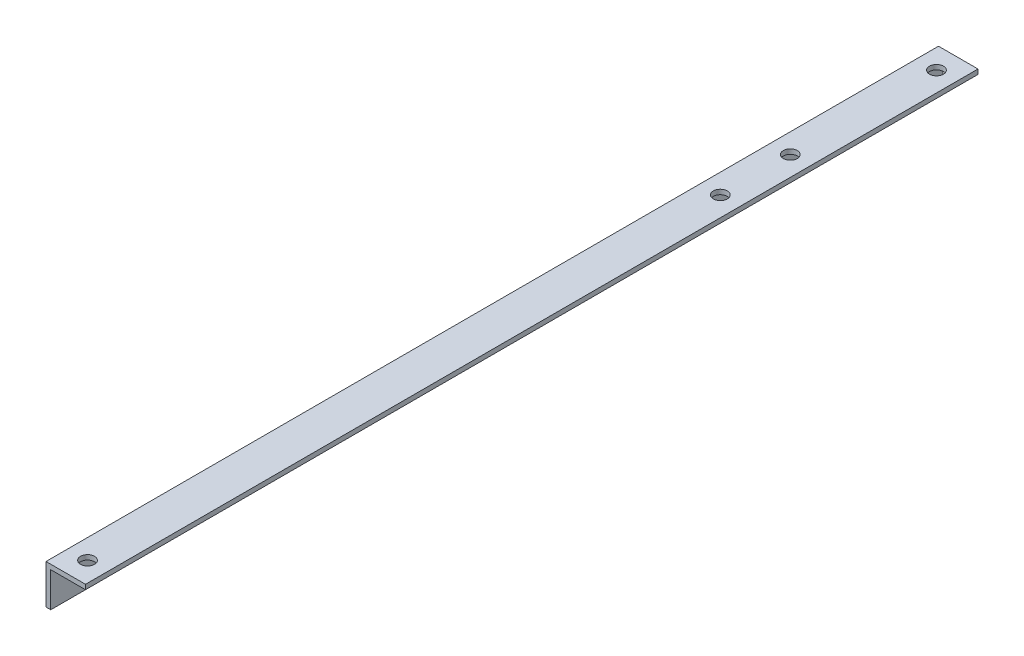
from build123d import *

# Parameters (mm, degrees)
BOSS_EXTRUDE1_DEPTH  = 287
M4_CLEARANCE_HOLE1_D = 4.5
M4_CLEARANCE_HOLE2_D = 4.5


with BuildPart() as part:
    # Sketch1 → Boss-Extrude1 (new body)
    with BuildSketch(Plane.XY):
        Polygon((0, 0), (12.7, 0), (12.7, -1.524), (1.524, -1.524), (1.524, -12.7), (0, -12.7), align=None)
    extrude(amount=BOSS_EXTRUDE1_DEPTH)

    # M4 Clearance Hole1 (through all)
    with Locations(Plane(origin=(0, 0, 0), x_dir=(1, 0, 0), z_dir=(0, 1, 0))):
        with Locations((6.35, -7), (6.35, -280), (6.35, -54), (6.35, -76.5)):
            Hole(M4_CLEARANCE_HOLE1_D / 2)

    # M4 Clearance Hole2 (through all)
    with Locations(Plane.ZY):
        with Locations((125, -6.35), (65, -6.35), (185, -6.35)):
            Hole(M4_CLEARANCE_HOLE2_D / 2)


solid = part.part
